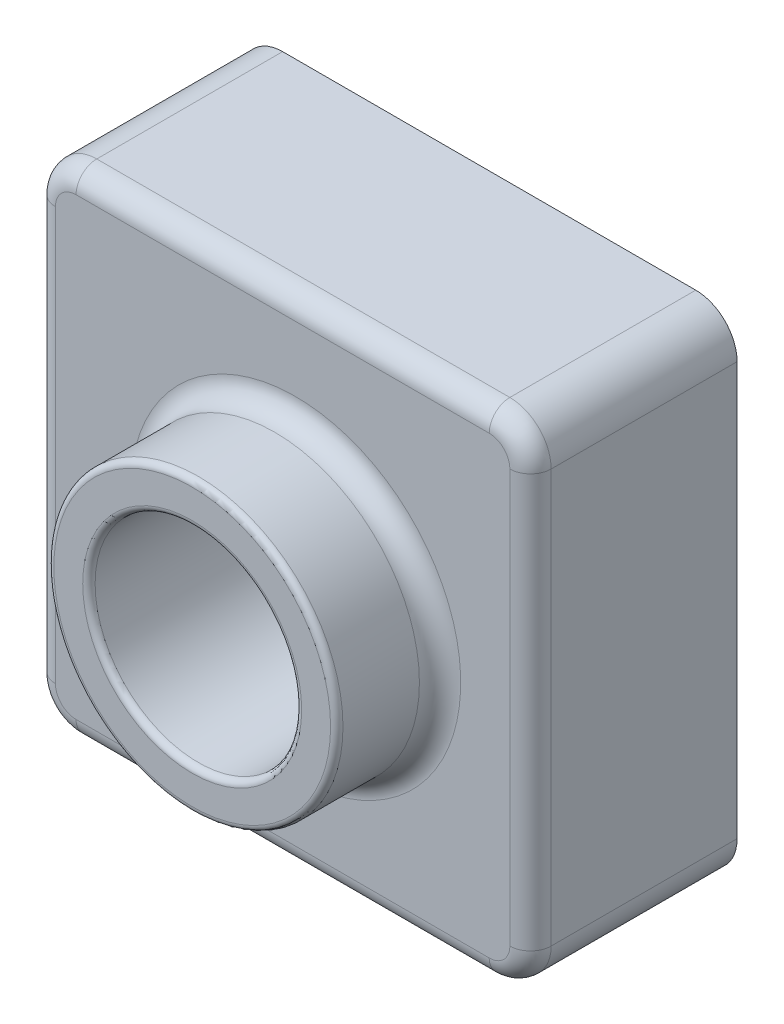
from build123d import *

# Parameters (mm, degrees)
SKETCH1_W           = 120
SKETCH1_H           = 120
BOSS_EXTRUDE1_DEPTH = 50
SKETCH2_R           = 35
BOSS_EXTRUDE2_DEPTH = 25
SKETCH3_R           = 25
CUT_EXTRUDE1_DEPTH  = 76
FILLET1_R           = 10
FILLET5_R           = 1.5
FILLET6_R           = 5
SHELL1_T            = -2


with BuildPart() as part:
    # Sketch1 → Boss-Extrude1 (new body)
    with BuildSketch(Plane.XY):
        with Locations((60, 60)):
            Rectangle(SKETCH1_W, SKETCH1_H)
    extrude(amount=BOSS_EXTRUDE1_DEPTH)

    # Sketch2 → Boss-Extrude2 (add)
    with BuildSketch(Plane.XY.offset(50)):
        with Locations((63.104995211, 59.260715426)):
            Circle(SKETCH2_R)
    extrude(amount=BOSS_EXTRUDE2_DEPTH)

    # Sketch3 → Cut-Extrude1 (cut, through all)
    with BuildSketch(Plane.XY.offset(75)):
        with Locations((63.104995211, 59.260715426)):
            Circle(SKETCH3_R)
    extrude(amount=-CUT_EXTRUDE1_DEPTH, mode=Mode.SUBTRACT)

    # Fillet1
    fillet1_edges = [part.edges().sort_by_distance(p)[0] for p in [
        (0, 120, 25),
        (120, 120, 25),
        (120, 0, 25),
        (0, 0, 25),
    ]]
    fillet(fillet1_edges, radius=FILLET1_R)

    # Fillet5
    fillet5_edges = [part.edges().sort_by_distance(p)[0] for p in [
        (28.104995211, 59.260715426, 75),
        (38.104995211, 59.260715426, 75),
    ]]
    fillet(fillet5_edges, radius=FILLET5_R)

    # Fillet6
    fillet6_edges = [part.edges().sort_by_distance(p)[0] for p in [
        (28.104995211, 59.260715426, 50),
        (60, 0, 50),
        (0, 60, 50),
        (120, 60, 50),
        (60, 120, 50),
        (117.071067812, 117.071067812, 50),
        (117.071067812, 2.928932188, 50),
        (2.928932188, 117.071067812, 50),
        (2.928932188, 2.928932188, 50),
    ]]
    fillet(fillet6_edges, radius=FILLET6_R)

    # Shell1
    shell1_openings = [part.faces().sort_by_distance(p)[0] for p in [
        (88.104995211, 59.260715426, 0),
    ]]
    offset(amount=SHELL1_T, openings=shell1_openings, kind=Kind.INTERSECTION)


solid = part.part
